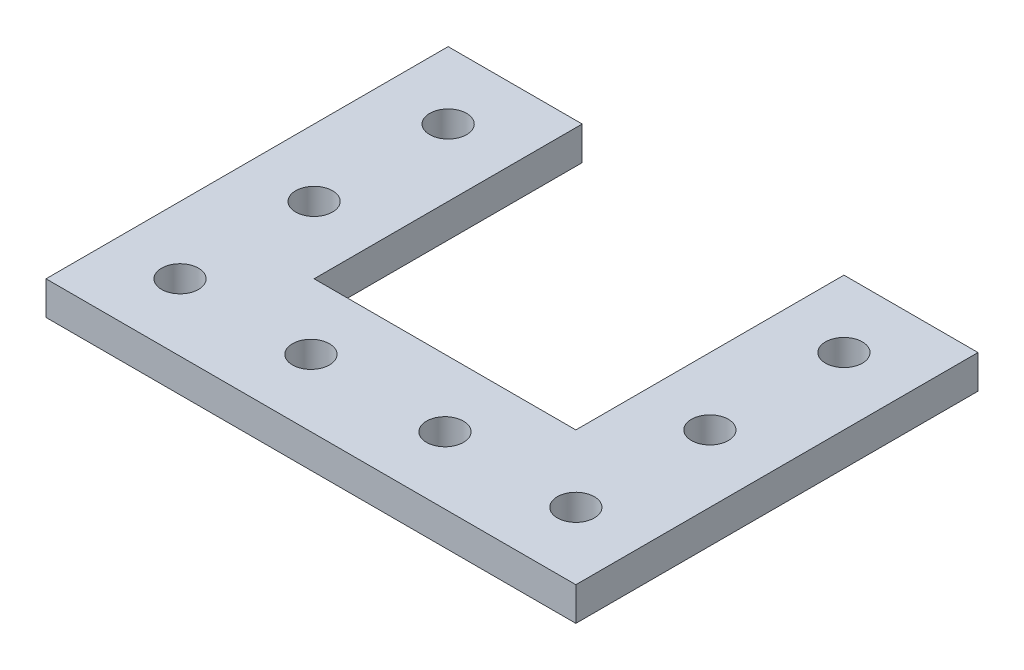
from build123d import *

# Parameters (mm, degrees)
BOSS_EXTRUDE1_DEPTH = 6.35
SKETCH2_R           = 3.5
CUT_EXTRUDE1_DEPTH  = 6.35


with BuildPart() as part:
    # Sketch1 → Boss-Extrude1 (new body)
    with BuildSketch(Plane(origin=(0, 0, 0), x_dir=(1, 0, 0), z_dir=(0, 1, 0))):
        Polygon((0, 76.2), (0, 0), (25.4, 0), (75, 0), (100.4, 0), (100.4, 76.2), (75, 76.2), (75, 25.4), (25.4, 25.4), (25.4, 76.2), align=None)
    extrude(amount=BOSS_EXTRUDE1_DEPTH)

    # Sketch2 → Cut-Extrude1 (cut)
    with BuildSketch(Plane(origin=(0, 6.35, 0), x_dir=(1, 0, 0), z_dir=(0, 1, 0))):
        with Locations((12.7, 12.7)):
            Circle(SKETCH2_R)
        with Locations((12.7, 38.1)):
            Circle(SKETCH2_R)
        with Locations((12.7, 63.5)):
            Circle(SKETCH2_R)
        with Locations((87.7, 63.5)):
            Circle(SKETCH2_R)
        with Locations((87.7, 38.1)):
            Circle(SKETCH2_R)
        with Locations((87.7, 12.7)):
            Circle(SKETCH2_R)
        with Locations((37.5, 12.7)):
            Circle(SKETCH2_R)
        with Locations((62.9, 12.7)):
            Circle(SKETCH2_R)
    extrude(amount=-CUT_EXTRUDE1_DEPTH, mode=Mode.SUBTRACT)


solid = part.part
